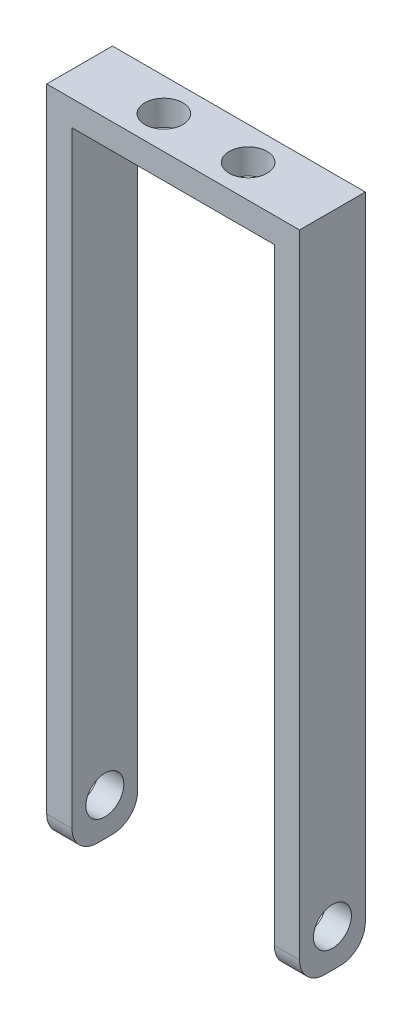
from build123d import *

# Parameters (mm, degrees)
SKETCH1_W               = 30
SKETCH1_H               = 7.8
BOSS_EXTRUDE1_DEPTH     = 3
CUT_EXTRUDE1_REACH      = 5
SKETCH2_R               = 2.25
SKETCH3_W               = 3
SKETCH3_H               = 7.8
BOSS_EXTRUDE2_DEPTH     = 75
SKETCH4_R               = 2.25
CUT_EXTRUDE2_DEPTH      = 1
CUT_EXTRUDE2_DEPTH_BACK = 31
FILLET1_R               = 3


with BuildPart() as part:
    # Sketch1 → Boss-Extrude1 (new body)
    with BuildSketch(Plane(origin=(0, 0, 0), x_dir=(1, 0, 0), z_dir=(0, 1, 0))):
        Rectangle(SKETCH1_W, SKETCH1_H)
    extrude(amount=-BOSS_EXTRUDE1_DEPTH)

    # Sketch2 → Cut-Extrude1 (cut, up to next)
    with BuildSketch(Plane(origin=(0, 0, 0), x_dir=(1, 0, 0), z_dir=(0, 1, 0)), mode=Mode.PRIVATE) as cut_extrude1_sk1:
        with Locations((-5, 0)):
            Circle(SKETCH2_R)
    cut_extrude1_tool1 = extrude(cut_extrude1_sk1.sketch, amount=-CUT_EXTRUDE1_REACH, mode=Mode.PRIVATE) & part.part
    add(cut_extrude1_tool1.solids().sort_by_distance((-5, 0, 0))[0], mode=Mode.SUBTRACT)
    # Sketch2 → Cut-Extrude1 (cut, up to next)
    with BuildSketch(Plane(origin=(0, 0, 0), x_dir=(1, 0, 0), z_dir=(0, 1, 0)), mode=Mode.PRIVATE) as cut_extrude1_sk2:
        with Locations((5, 0)):
            Circle(SKETCH2_R)
    cut_extrude1_tool2 = extrude(cut_extrude1_sk2.sketch, amount=-CUT_EXTRUDE1_REACH, mode=Mode.PRIVATE) & part.part
    add(cut_extrude1_tool2.solids().sort_by_distance((5, 0, 0))[0], mode=Mode.SUBTRACT)

    # Sketch3 → Boss-Extrude2 (add)
    with BuildSketch(Plane.XZ.offset(3)):
        with Locations((-13.5, 0)):
            Rectangle(SKETCH3_W, SKETCH3_H)
        with Locations((13.5, 0)):
            Rectangle(SKETCH3_W, SKETCH3_H)
    extrude(amount=BOSS_EXTRUDE2_DEPTH)

    # Sketch4 → Cut-Extrude2 (cut, two sides)
    with BuildSketch(Plane(origin=(15, 0, 0), x_dir=(0, 0, -1), z_dir=(1, 0, 0))) as cut_extrude2_sk:
        with Locations((0, -73.5)):
            Circle(SKETCH4_R)
    extrude(amount=CUT_EXTRUDE2_DEPTH, mode=Mode.SUBTRACT)
    extrude(cut_extrude2_sk.sketch, amount=-CUT_EXTRUDE2_DEPTH_BACK, mode=Mode.SUBTRACT)

    # Fillet1
    fillet1_edges = [part.edges().sort_by_distance(p)[0] for p in [
        (-13.5, -78, -3.9),
        (-13.5, -78, 3.9),
        (13.5, -78, 3.9),
        (13.5, -78, -3.9),
    ]]
    fillet(fillet1_edges, radius=FILLET1_R)


solid = part.part
